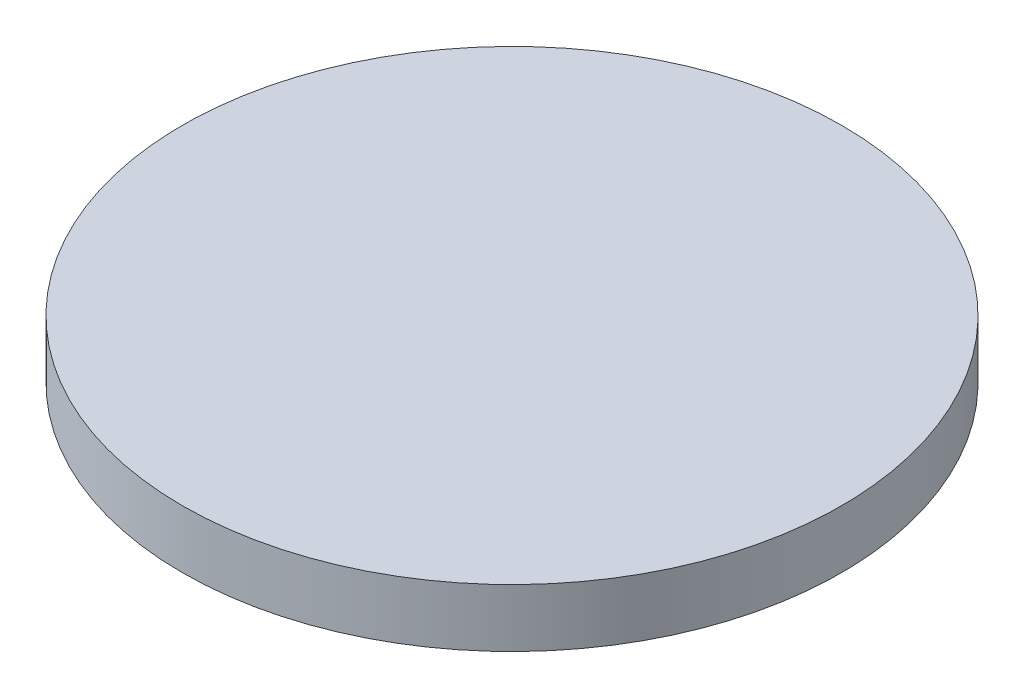
from build123d import *

# Parameters (mm, degrees)
SKETCH_1_R      = 6.25
EXTRUDE_1_DEPTH = 1.1


with BuildPart() as part:
    # 草图1 → 凸台-拉伸1 (new body)
    with BuildSketch(Plane(origin=(0, 0, 0), x_dir=(1, 0, 0), z_dir=(0, 1, 0))):
        with Locations(Location((0, 0, 0), (0, 0, 270))):  # turned: the seam where the file's is
            Circle(SKETCH_1_R)
    extrude(amount=EXTRUDE_1_DEPTH)


solid = part.part
